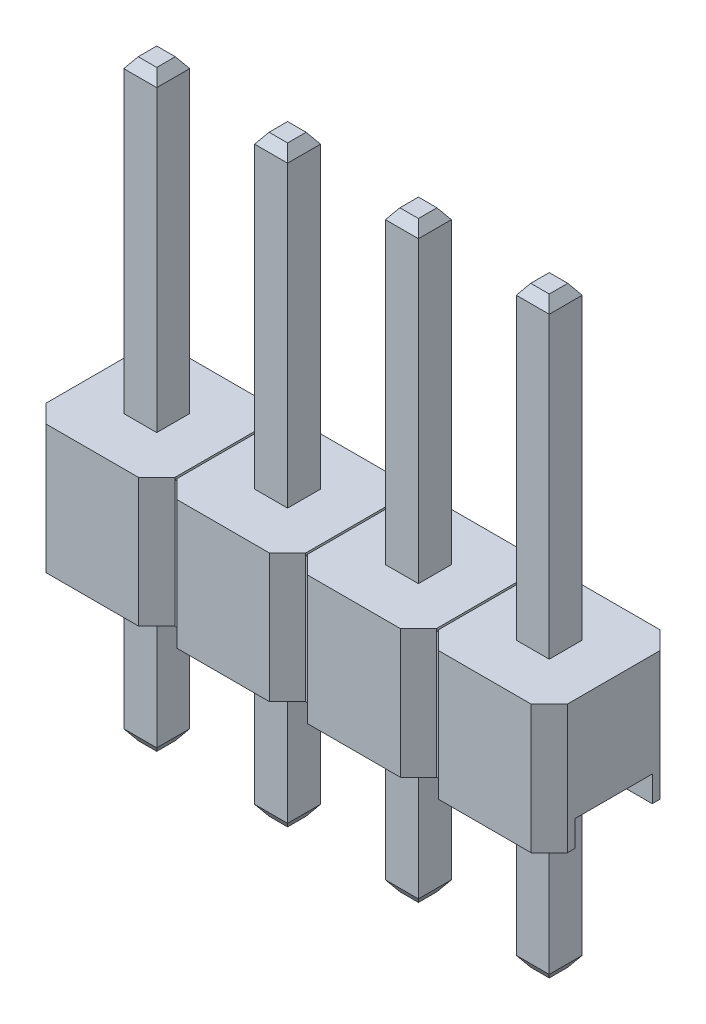
from build123d import *
from OCP.BRepFilletAPI import BRepFilletAPI_MakeChamfer

# Parameters (mm, degrees)
BOSS_EXTRUDE1_DEPTH         = 2.5
SKETCH2_W                   = 10.12
SKETCH2_H                   = 1.5
CUT_EXTRUDE1_DEPTH          = 0.5
SKETCH4_W                   = 0.04
SKETCH4_H                   = 1.8
CUT_EXTRUDE2_DEPTH          = 0.04
BOSS_EXTRUDE2_START         = -5.5
SKETCH3_W                   = 0.64
SKETCH3_H                   = 0.64
BOSS_EXTRUDE2_DEPTH         = 11.5
CHAMFER1_SIZE               = 0.2
CHAMFER1_SIZE2              = 0.140041508
LPATTERN1_COUNT             = 4
LPATTERN1_PITCH             = 2.54
CHAMFER1_OF_LPATTERN1_SIZE  = 0.2
CHAMFER1_OF_LPATTERN1_SIZE2 = 0.140041508


with BuildPart() as part:
    # Sketch1 → Boss-Extrude1 (new body)
    with BuildSketch(Plane(origin=(0, 0, 0), x_dir=(1, 0, 0), z_dir=(0, 1, 0))):
        Polygon((0, 2.15), (0.35, 2.5), (2.15, 2.5), (2.5, 2.15), (2.54, 2.15), (2.89, 2.5), (4.69, 2.5), (5.04, 2.15), (5.08, 2.15), (5.43, 2.5), (7.23, 2.5), (7.58, 2.15), (7.62, 2.15), (7.97, 2.5), (9.77, 2.5), (10.12, 2.15), (10.12, 0.35), (9.77, 0), (7.97, 0), (7.62, 0.35), (7.58, 0.35), (7.23, 0), (5.43, 0), (5.08, 0.35), (5.04, 0.35), (4.69, 0), (2.89, 0), (2.54, 0.35), (2.5, 0.35), (2.15, 0), (0.35, 0), (0, 0.35), align=None)
    extrude(amount=BOSS_EXTRUDE1_DEPTH)

    # Sketch2 → Cut-Extrude1 (cut)
    with BuildSketch(Plane.XZ):
        with Locations((5.06, -1.25)):
            Rectangle(SKETCH2_W, SKETCH2_H)
    extrude(amount=-CUT_EXTRUDE1_DEPTH, mode=Mode.SUBTRACT)

    # Sketch4 → Cut-Extrude2 (cut)
    with BuildSketch(Plane(origin=(0, 2.5, 0), x_dir=(1, 0, 0), z_dir=(0, 1, 0))):
        with Locations((5.06, 1.25)):
            Rectangle(SKETCH4_W, SKETCH4_H)
        with Locations((2.52, 1.25)):
            Rectangle(SKETCH4_W, SKETCH4_H)
        with Locations((7.6, 1.25)):
            Rectangle(SKETCH4_W, SKETCH4_H)
        with Locations((10.14, 1.25)):
            Rectangle(SKETCH4_W, SKETCH4_H)
        with Locations((12.68, 1.25)):
            Rectangle(SKETCH4_W, SKETCH4_H)
        with Locations((15.22, 1.25)):
            Rectangle(SKETCH4_W, SKETCH4_H)
        with Locations((17.76, 1.25)):
            Rectangle(SKETCH4_W, SKETCH4_H)
    extrude(amount=-CUT_EXTRUDE2_DEPTH, mode=Mode.SUBTRACT)

    # Sketch3 → Boss-Extrude2 (add)
    with BuildSketch(Plane(origin=(0, 2.5, 0), x_dir=(1, 0, 0), z_dir=(0, 1, 0)).offset(BOSS_EXTRUDE2_START)):
        with Locations((1.25, 1.25)):
            Rectangle(SKETCH3_W, SKETCH3_H)
    boss_extrude2 = extrude(amount=BOSS_EXTRUDE2_DEPTH)

    # Chamfer1: one chamfer whose edges measure the first distance from different faces: ONE call of the kernel's chamfer builder (chamfer() names one face for all edges)
    chamfer1_edges_1 = [part.edges().sort_by_distance(p)[0] for p in [
        (1.57, -3, -1.25),
    ]]
    chamfer1_side_1 = [part.faces().sort_by_distance(p)[0] for p in [
        (1.57, -1.25, -1.25),
    ]]
    chamfer1_edges_2 = [part.edges().sort_by_distance(p)[0] for p in [
        (1.25, -3, -0.93),
    ]]
    chamfer1_side_2 = [part.faces().sort_by_distance(p)[0] for p in [
        (1.25, -1.25, -0.93),
    ]]
    chamfer1_edges_3 = [part.edges().sort_by_distance(p)[0] for p in [
        (0.93, -3, -1.25),
    ]]
    chamfer1_side_3 = [part.faces().sort_by_distance(p)[0] for p in [
        (0.93, -1.25, -1.25),
    ]]
    chamfer1_edges_4 = [part.edges().sort_by_distance(p)[0] for p in [
        (1.25, -3, -1.57),
    ]]
    chamfer1_side_4 = [part.faces().sort_by_distance(p)[0] for p in [
        (1.25, -1.25, -1.57),
    ]]
    chamfer1_edges_5 = [part.edges().sort_by_distance(p)[0] for p in [
        (1.57, 8.5, -1.25),
    ]]
    chamfer1_side_5 = [part.faces().sort_by_distance(p)[0] for p in [
        (1.57, 5.5, -1.25),
    ]]
    chamfer1_edges_6 = [part.edges().sort_by_distance(p)[0] for p in [
        (1.25, 8.5, -1.57),
    ]]
    chamfer1_side_6 = [part.faces().sort_by_distance(p)[0] for p in [
        (1.25, 5.5, -1.57),
    ]]
    chamfer1_edges_7 = [part.edges().sort_by_distance(p)[0] for p in [
        (0.93, 8.5, -1.25),
    ]]
    chamfer1_side_7 = [part.faces().sort_by_distance(p)[0] for p in [
        (0.93, 5.5, -1.25),
    ]]
    chamfer1_edges_8 = [part.edges().sort_by_distance(p)[0] for p in [
        (1.25, 8.5, -0.93),
    ]]
    chamfer1_side_8 = [part.faces().sort_by_distance(p)[0] for p in [
        (1.25, 5.5, -0.93),
    ]]
    chamfer1 = BRepFilletAPI_MakeChamfer(part.part.solid().wrapped)
    for e in chamfer1_edges_1:
        chamfer1.Add(CHAMFER1_SIZE, CHAMFER1_SIZE2, e.wrapped, chamfer1_side_1[0].wrapped)  # the first distance lies on this face
    for e in chamfer1_edges_2:
        chamfer1.Add(CHAMFER1_SIZE, CHAMFER1_SIZE2, e.wrapped, chamfer1_side_2[0].wrapped)  # the first distance lies on this face
    for e in chamfer1_edges_3:
        chamfer1.Add(CHAMFER1_SIZE, CHAMFER1_SIZE2, e.wrapped, chamfer1_side_3[0].wrapped)  # the first distance lies on this face
    for e in chamfer1_edges_4:
        chamfer1.Add(CHAMFER1_SIZE, CHAMFER1_SIZE2, e.wrapped, chamfer1_side_4[0].wrapped)  # the first distance lies on this face
    for e in chamfer1_edges_5:
        chamfer1.Add(CHAMFER1_SIZE, CHAMFER1_SIZE2, e.wrapped, chamfer1_side_5[0].wrapped)  # the first distance lies on this face
    for e in chamfer1_edges_6:
        chamfer1.Add(CHAMFER1_SIZE, CHAMFER1_SIZE2, e.wrapped, chamfer1_side_6[0].wrapped)  # the first distance lies on this face
    for e in chamfer1_edges_7:
        chamfer1.Add(CHAMFER1_SIZE, CHAMFER1_SIZE2, e.wrapped, chamfer1_side_7[0].wrapped)  # the first distance lies on this face
    for e in chamfer1_edges_8:
        chamfer1.Add(CHAMFER1_SIZE, CHAMFER1_SIZE2, e.wrapped, chamfer1_side_8[0].wrapped)  # the first distance lies on this face
    add(Compound.cast(chamfer1.Shape()), mode=Mode.REPLACE)

    # LPattern1: Boss-Extrude2 ×4
    with Locations(*[(i * LPATTERN1_PITCH, 0, 0) for i in range(1, LPATTERN1_COUNT)]):
        add(boss_extrude2)

    # Chamfer1 of LPattern1: one chamfer whose edges measure the first distance from different faces: ONE call of the kernel's chamfer builder (chamfer() names one face for all edges)
    chamfer1_of_lpattern1_edges_1 = [part.edges().sort_by_distance(p)[0] for p in [
        (4.11, -3, -1.25),
    ]]
    chamfer1_of_lpattern1_side_1 = [part.faces().sort_by_distance(p)[0] for p in [
        (4.11, -1.25, -1.25),
    ]]
    chamfer1_of_lpattern1_edges_2 = [part.edges().sort_by_distance(p)[0] for p in [
        (3.79, -3, -0.93),
    ]]
    chamfer1_of_lpattern1_side_2 = [part.faces().sort_by_distance(p)[0] for p in [
        (3.79, -1.25, -0.93),
    ]]
    chamfer1_of_lpattern1_edges_3 = [part.edges().sort_by_distance(p)[0] for p in [
        (3.47, -3, -1.25),
    ]]
    chamfer1_of_lpattern1_side_3 = [part.faces().sort_by_distance(p)[0] for p in [
        (3.47, -1.25, -1.25),
    ]]
    chamfer1_of_lpattern1_edges_4 = [part.edges().sort_by_distance(p)[0] for p in [
        (3.79, -3, -1.57),
    ]]
    chamfer1_of_lpattern1_side_4 = [part.faces().sort_by_distance(p)[0] for p in [
        (3.79, -1.25, -1.57),
    ]]
    chamfer1_of_lpattern1_edges_5 = [part.edges().sort_by_distance(p)[0] for p in [
        (4.11, 8.5, -1.25),
    ]]
    chamfer1_of_lpattern1_side_5 = [part.faces().sort_by_distance(p)[0] for p in [
        (4.11, 5.5, -1.25),
    ]]
    chamfer1_of_lpattern1_edges_6 = [part.edges().sort_by_distance(p)[0] for p in [
        (3.79, 8.5, -1.57),
    ]]
    chamfer1_of_lpattern1_side_6 = [part.faces().sort_by_distance(p)[0] for p in [
        (3.79, 5.5, -1.57),
    ]]
    chamfer1_of_lpattern1_edges_7 = [part.edges().sort_by_distance(p)[0] for p in [
        (3.47, 8.5, -1.25),
    ]]
    chamfer1_of_lpattern1_side_7 = [part.faces().sort_by_distance(p)[0] for p in [
        (3.47, 5.5, -1.25),
    ]]
    chamfer1_of_lpattern1_edges_8 = [part.edges().sort_by_distance(p)[0] for p in [
        (3.79, 8.5, -0.93),
    ]]
    chamfer1_of_lpattern1_side_8 = [part.faces().sort_by_distance(p)[0] for p in [
        (3.79, 5.5, -0.93),
    ]]
    chamfer1_of_lpattern1_edges_9 = [part.edges().sort_by_distance(p)[0] for p in [
        (6.65, -3, -1.25),
    ]]
    chamfer1_of_lpattern1_side_9 = [part.faces().sort_by_distance(p)[0] for p in [
        (6.65, -1.25, -1.25),
    ]]
    chamfer1_of_lpattern1_edges_10 = [part.edges().sort_by_distance(p)[0] for p in [
        (6.33, -3, -0.93),
    ]]
    chamfer1_of_lpattern1_side_10 = [part.faces().sort_by_distance(p)[0] for p in [
        (6.33, -1.25, -0.93),
    ]]
    chamfer1_of_lpattern1_edges_11 = [part.edges().sort_by_distance(p)[0] for p in [
        (6.01, -3, -1.25),
    ]]
    chamfer1_of_lpattern1_side_11 = [part.faces().sort_by_distance(p)[0] for p in [
        (6.01, -1.25, -1.25),
    ]]
    chamfer1_of_lpattern1_edges_12 = [part.edges().sort_by_distance(p)[0] for p in [
        (6.33, -3, -1.57),
    ]]
    chamfer1_of_lpattern1_side_12 = [part.faces().sort_by_distance(p)[0] for p in [
        (6.33, -1.25, -1.57),
    ]]
    chamfer1_of_lpattern1_edges_13 = [part.edges().sort_by_distance(p)[0] for p in [
        (6.65, 8.5, -1.25),
    ]]
    chamfer1_of_lpattern1_side_13 = [part.faces().sort_by_distance(p)[0] for p in [
        (6.65, 5.5, -1.25),
    ]]
    chamfer1_of_lpattern1_edges_14 = [part.edges().sort_by_distance(p)[0] for p in [
        (6.33, 8.5, -1.57),
    ]]
    chamfer1_of_lpattern1_side_14 = [part.faces().sort_by_distance(p)[0] for p in [
        (6.33, 5.5, -1.57),
    ]]
    chamfer1_of_lpattern1_edges_15 = [part.edges().sort_by_distance(p)[0] for p in [
        (6.01, 8.5, -1.25),
    ]]
    chamfer1_of_lpattern1_side_15 = [part.faces().sort_by_distance(p)[0] for p in [
        (6.01, 5.5, -1.25),
    ]]
    chamfer1_of_lpattern1_edges_16 = [part.edges().sort_by_distance(p)[0] for p in [
        (6.33, 8.5, -0.93),
    ]]
    chamfer1_of_lpattern1_side_16 = [part.faces().sort_by_distance(p)[0] for p in [
        (6.33, 5.5, -0.93),
    ]]
    chamfer1_of_lpattern1_edges_17 = [part.edges().sort_by_distance(p)[0] for p in [
        (9.19, -3, -1.25),
    ]]
    chamfer1_of_lpattern1_side_17 = [part.faces().sort_by_distance(p)[0] for p in [
        (9.19, -1.25, -1.25),
    ]]
    chamfer1_of_lpattern1_edges_18 = [part.edges().sort_by_distance(p)[0] for p in [
        (8.87, -3, -0.93),
    ]]
    chamfer1_of_lpattern1_side_18 = [part.faces().sort_by_distance(p)[0] for p in [
        (8.87, -1.25, -0.93),
    ]]
    chamfer1_of_lpattern1_edges_19 = [part.edges().sort_by_distance(p)[0] for p in [
        (8.55, -3, -1.25),
    ]]
    chamfer1_of_lpattern1_side_19 = [part.faces().sort_by_distance(p)[0] for p in [
        (8.55, -1.25, -1.25),
    ]]
    chamfer1_of_lpattern1_edges_20 = [part.edges().sort_by_distance(p)[0] for p in [
        (8.87, -3, -1.57),
    ]]
    chamfer1_of_lpattern1_side_20 = [part.faces().sort_by_distance(p)[0] for p in [
        (8.87, -1.25, -1.57),
    ]]
    chamfer1_of_lpattern1_edges_21 = [part.edges().sort_by_distance(p)[0] for p in [
        (9.19, 8.5, -1.25),
    ]]
    chamfer1_of_lpattern1_side_21 = [part.faces().sort_by_distance(p)[0] for p in [
        (9.19, 5.5, -1.25),
    ]]
    chamfer1_of_lpattern1_edges_22 = [part.edges().sort_by_distance(p)[0] for p in [
        (8.87, 8.5, -1.57),
    ]]
    chamfer1_of_lpattern1_side_22 = [part.faces().sort_by_distance(p)[0] for p in [
        (8.87, 5.5, -1.57),
    ]]
    chamfer1_of_lpattern1_edges_23 = [part.edges().sort_by_distance(p)[0] for p in [
        (8.55, 8.5, -1.25),
    ]]
    chamfer1_of_lpattern1_side_23 = [part.faces().sort_by_distance(p)[0] for p in [
        (8.55, 5.5, -1.25),
    ]]
    chamfer1_of_lpattern1_edges_24 = [part.edges().sort_by_distance(p)[0] for p in [
        (8.87, 8.5, -0.93),
    ]]
    chamfer1_of_lpattern1_side_24 = [part.faces().sort_by_distance(p)[0] for p in [
        (8.87, 5.5, -0.93),
    ]]
    chamfer1_of_lpattern1 = BRepFilletAPI_MakeChamfer(part.part.solid().wrapped)
    for e in chamfer1_of_lpattern1_edges_1:
        chamfer1_of_lpattern1.Add(CHAMFER1_OF_LPATTERN1_SIZE, CHAMFER1_OF_LPATTERN1_SIZE2, e.wrapped, chamfer1_of_lpattern1_side_1[0].wrapped)  # the first distance lies on this face
    for e in chamfer1_of_lpattern1_edges_2:
        chamfer1_of_lpattern1.Add(CHAMFER1_OF_LPATTERN1_SIZE, CHAMFER1_OF_LPATTERN1_SIZE2, e.wrapped, chamfer1_of_lpattern1_side_2[0].wrapped)  # the first distance lies on this face
    for e in chamfer1_of_lpattern1_edges_3:
        chamfer1_of_lpattern1.Add(CHAMFER1_OF_LPATTERN1_SIZE, CHAMFER1_OF_LPATTERN1_SIZE2, e.wrapped, chamfer1_of_lpattern1_side_3[0].wrapped)  # the first distance lies on this face
    for e in chamfer1_of_lpattern1_edges_4:
        chamfer1_of_lpattern1.Add(CHAMFER1_OF_LPATTERN1_SIZE, CHAMFER1_OF_LPATTERN1_SIZE2, e.wrapped, chamfer1_of_lpattern1_side_4[0].wrapped)  # the first distance lies on this face
    for e in chamfer1_of_lpattern1_edges_5:
        chamfer1_of_lpattern1.Add(CHAMFER1_OF_LPATTERN1_SIZE, CHAMFER1_OF_LPATTERN1_SIZE2, e.wrapped, chamfer1_of_lpattern1_side_5[0].wrapped)  # the first distance lies on this face
    for e in chamfer1_of_lpattern1_edges_6:
        chamfer1_of_lpattern1.Add(CHAMFER1_OF_LPATTERN1_SIZE, CHAMFER1_OF_LPATTERN1_SIZE2, e.wrapped, chamfer1_of_lpattern1_side_6[0].wrapped)  # the first distance lies on this face
    for e in chamfer1_of_lpattern1_edges_7:
        chamfer1_of_lpattern1.Add(CHAMFER1_OF_LPATTERN1_SIZE, CHAMFER1_OF_LPATTERN1_SIZE2, e.wrapped, chamfer1_of_lpattern1_side_7[0].wrapped)  # the first distance lies on this face
    for e in chamfer1_of_lpattern1_edges_8:
        chamfer1_of_lpattern1.Add(CHAMFER1_OF_LPATTERN1_SIZE, CHAMFER1_OF_LPATTERN1_SIZE2, e.wrapped, chamfer1_of_lpattern1_side_8[0].wrapped)  # the first distance lies on this face
    for e in chamfer1_of_lpattern1_edges_9:
        chamfer1_of_lpattern1.Add(CHAMFER1_OF_LPATTERN1_SIZE, CHAMFER1_OF_LPATTERN1_SIZE2, e.wrapped, chamfer1_of_lpattern1_side_9[0].wrapped)  # the first distance lies on this face
    for e in chamfer1_of_lpattern1_edges_10:
        chamfer1_of_lpattern1.Add(CHAMFER1_OF_LPATTERN1_SIZE, CHAMFER1_OF_LPATTERN1_SIZE2, e.wrapped, chamfer1_of_lpattern1_side_10[0].wrapped)  # the first distance lies on this face
    for e in chamfer1_of_lpattern1_edges_11:
        chamfer1_of_lpattern1.Add(CHAMFER1_OF_LPATTERN1_SIZE, CHAMFER1_OF_LPATTERN1_SIZE2, e.wrapped, chamfer1_of_lpattern1_side_11[0].wrapped)  # the first distance lies on this face
    for e in chamfer1_of_lpattern1_edges_12:
        chamfer1_of_lpattern1.Add(CHAMFER1_OF_LPATTERN1_SIZE, CHAMFER1_OF_LPATTERN1_SIZE2, e.wrapped, chamfer1_of_lpattern1_side_12[0].wrapped)  # the first distance lies on this face
    for e in chamfer1_of_lpattern1_edges_13:
        chamfer1_of_lpattern1.Add(CHAMFER1_OF_LPATTERN1_SIZE, CHAMFER1_OF_LPATTERN1_SIZE2, e.wrapped, chamfer1_of_lpattern1_side_13[0].wrapped)  # the first distance lies on this face
    for e in chamfer1_of_lpattern1_edges_14:
        chamfer1_of_lpattern1.Add(CHAMFER1_OF_LPATTERN1_SIZE, CHAMFER1_OF_LPATTERN1_SIZE2, e.wrapped, chamfer1_of_lpattern1_side_14[0].wrapped)  # the first distance lies on this face
    for e in chamfer1_of_lpattern1_edges_15:
        chamfer1_of_lpattern1.Add(CHAMFER1_OF_LPATTERN1_SIZE, CHAMFER1_OF_LPATTERN1_SIZE2, e.wrapped, chamfer1_of_lpattern1_side_15[0].wrapped)  # the first distance lies on this face
    for e in chamfer1_of_lpattern1_edges_16:
        chamfer1_of_lpattern1.Add(CHAMFER1_OF_LPATTERN1_SIZE, CHAMFER1_OF_LPATTERN1_SIZE2, e.wrapped, chamfer1_of_lpattern1_side_16[0].wrapped)  # the first distance lies on this face
    for e in chamfer1_of_lpattern1_edges_17:
        chamfer1_of_lpattern1.Add(CHAMFER1_OF_LPATTERN1_SIZE, CHAMFER1_OF_LPATTERN1_SIZE2, e.wrapped, chamfer1_of_lpattern1_side_17[0].wrapped)  # the first distance lies on this face
    for e in chamfer1_of_lpattern1_edges_18:
        chamfer1_of_lpattern1.Add(CHAMFER1_OF_LPATTERN1_SIZE, CHAMFER1_OF_LPATTERN1_SIZE2, e.wrapped, chamfer1_of_lpattern1_side_18[0].wrapped)  # the first distance lies on this face
    for e in chamfer1_of_lpattern1_edges_19:
        chamfer1_of_lpattern1.Add(CHAMFER1_OF_LPATTERN1_SIZE, CHAMFER1_OF_LPATTERN1_SIZE2, e.wrapped, chamfer1_of_lpattern1_side_19[0].wrapped)  # the first distance lies on this face
    for e in chamfer1_of_lpattern1_edges_20:
        chamfer1_of_lpattern1.Add(CHAMFER1_OF_LPATTERN1_SIZE, CHAMFER1_OF_LPATTERN1_SIZE2, e.wrapped, chamfer1_of_lpattern1_side_20[0].wrapped)  # the first distance lies on this face
    for e in chamfer1_of_lpattern1_edges_21:
        chamfer1_of_lpattern1.Add(CHAMFER1_OF_LPATTERN1_SIZE, CHAMFER1_OF_LPATTERN1_SIZE2, e.wrapped, chamfer1_of_lpattern1_side_21[0].wrapped)  # the first distance lies on this face
    for e in chamfer1_of_lpattern1_edges_22:
        chamfer1_of_lpattern1.Add(CHAMFER1_OF_LPATTERN1_SIZE, CHAMFER1_OF_LPATTERN1_SIZE2, e.wrapped, chamfer1_of_lpattern1_side_22[0].wrapped)  # the first distance lies on this face
    for e in chamfer1_of_lpattern1_edges_23:
        chamfer1_of_lpattern1.Add(CHAMFER1_OF_LPATTERN1_SIZE, CHAMFER1_OF_LPATTERN1_SIZE2, e.wrapped, chamfer1_of_lpattern1_side_23[0].wrapped)  # the first distance lies on this face
    for e in chamfer1_of_lpattern1_edges_24:
        chamfer1_of_lpattern1.Add(CHAMFER1_OF_LPATTERN1_SIZE, CHAMFER1_OF_LPATTERN1_SIZE2, e.wrapped, chamfer1_of_lpattern1_side_24[0].wrapped)  # the first distance lies on this face
    add(Compound.cast(chamfer1_of_lpattern1.Shape()), mode=Mode.REPLACE)


solid = part.part
